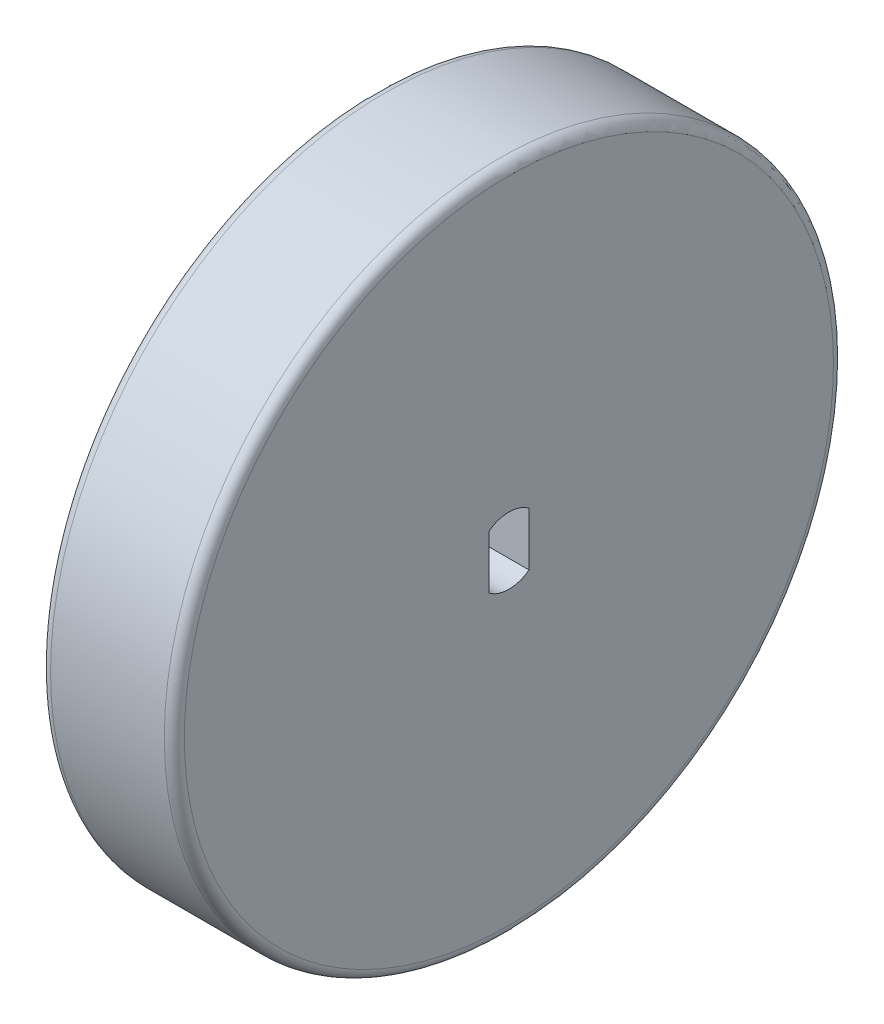
from build123d import *

# Parameters (mm, degrees)
SKETCH1_R           = 25.4
BOSS_EXTRUDE1_DEPTH = 10.16
FILLET1_R           = 0.762
CUT_EXTRUDE1_DEPTH  = 11.16


with BuildPart() as part:
    # Sketch1 → Boss-Extrude1 (new body)
    with BuildSketch(Plane(origin=(0, 0, 0), x_dir=(0, 0, -1), z_dir=(1, 0, 0))):
        Circle(SKETCH1_R)
    extrude(amount=BOSS_EXTRUDE1_DEPTH)

    # Fillet1
    fillet1_edges = [part.edges().sort_by_distance(p)[0] for p in [
        (0, 0, 25.4),
        (10.16, 0, 25.4),
    ]]
    fillet(fillet1_edges, radius=FILLET1_R)

    # Sketch2 → Cut-Extrude1 (cut, through all)
    with BuildSketch(Plane(origin=(10.16, 0, 0), x_dir=(0, 0, -1), z_dir=(1, 0, 0))):
        with BuildLine():
            Line((-1.524, -2.032), (-1.524, 2.032))
            ThreePointArc((-1.524, 2.032), (0, 2.54), (1.524, 2.032))
            Line((1.524, 2.032), (1.524, -2.032))
            ThreePointArc((1.524, -2.032), (0, -2.54), (-1.524, -2.032))
        make_face()
    extrude(amount=-CUT_EXTRUDE1_DEPTH, mode=Mode.SUBTRACT)


solid = part.part
